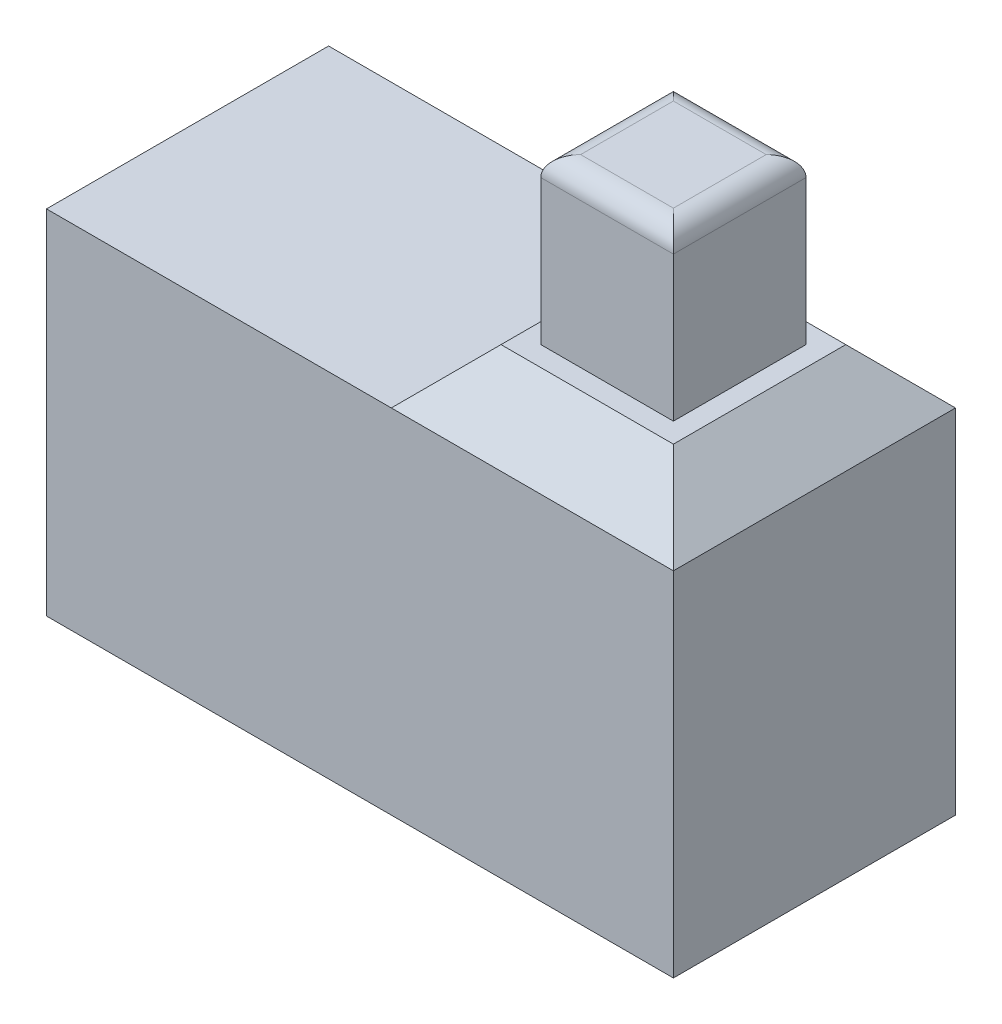
from build123d import *

# Parameters (mm, degrees)
SKETCH1_W           = 8
SKETCH1_H           = 3.6
BOSS_EXTRUDE1_DEPTH = 4.5
SKETCH2_W           = 3.6
SKETCH2_H           = 3.6
BOSS_EXTRUDE2_DEPTH = 0.7
BOSS_EXTRUDE2_TAPER = 45
SKETCH3_W           = 1.692
SKETCH3_H           = 1.692
BOSS_EXTRUDE3_DEPTH = 2.1
FILLET1_R           = 0.254


with BuildPart() as part:
    # Sketch1 → Boss-Extrude1 (new body)
    with BuildSketch(Plane(origin=(0, 0, 0), x_dir=(1, 0, 0), z_dir=(0, 1, 0))):
        Rectangle(SKETCH1_W, SKETCH1_H)
    extrude(amount=BOSS_EXTRUDE1_DEPTH)

    # Sketch2 → Boss-Extrude2 (add)
    with BuildSketch(Plane(origin=(0, 4.5, 0), x_dir=(1, 0, 0), z_dir=(0, 1, 0))):
        with Locations((2.2, 0)):
            Rectangle(SKETCH2_W, SKETCH2_H)
    extrude(amount=BOSS_EXTRUDE2_DEPTH, taper=BOSS_EXTRUDE2_TAPER)

    # Sketch3 → Boss-Extrude3 (add)
    with BuildSketch(Plane(origin=(0, 5.2, 0), x_dir=(1, 0, 0), z_dir=(0, 1, 0))):
        with Locations((2.2, 0)):
            Rectangle(SKETCH3_W, SKETCH3_H)
    extrude(amount=BOSS_EXTRUDE3_DEPTH)

    # Fillet1
    fillet1_edges = [part.edges().sort_by_distance(p)[0] for p in [
        (2.2, 7.3, 0.846),
        (3.046, 7.3, 0),
        (2.2, 7.3, -0.846),
        (1.354, 7.3, 0),
    ]]
    fillet(fillet1_edges, radius=FILLET1_R)


solid = part.part
